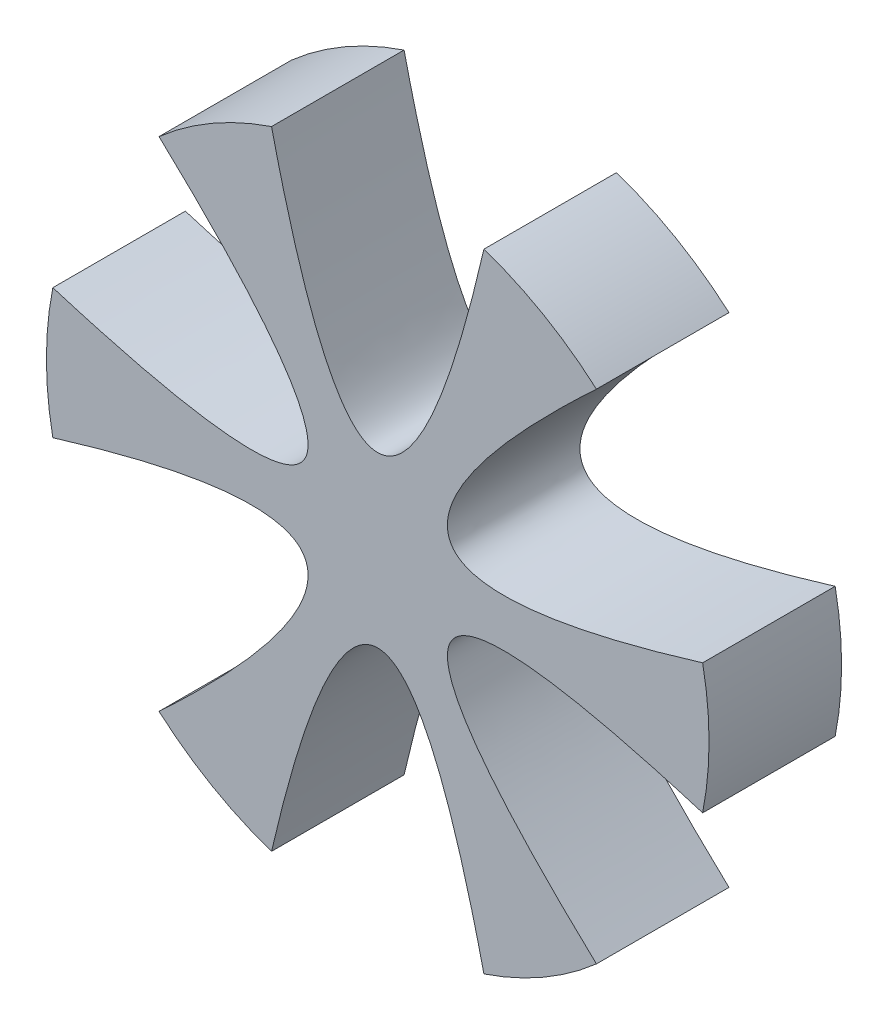
from build123d import *

# Parameters (mm, degrees)
SKETCH2_R           = 38.1
BOSS_EXTRUDE1_DEPTH = 2.54
BOSS_EXTRUDE2_DEPTH = 12.7
SKETCH4_R           = 1.524
CUT_EXTRUDE1_DEPTH  = 3.81
CUT_EXTRUDE2_DEPTH  = 46.228


with BuildPart() as part:
    # Sketch2 → Boss-Extrude1 (new body)
    with BuildSketch(Plane.XY):
        Circle(SKETCH2_R)
    extrude(amount=BOSS_EXTRUDE1_DEPTH)

    # Sketch3 → Boss-Extrude2 (add)
    with BuildSketch(Plane.XY.offset(2.54)):
        with BuildLine():
            ThreePointArc((-37.360397619, 7.470655243), (-38.1, 0), (-37.360397619, -7.470655243))
            add(Edge.make_bspline(
                [(-25.149976033, -28.619725812), (14.41186903, 8.320696464), (-37.360397619, -7.470655243)],
                knots=[0, 0, 0, 1, 1, 1], degree=2))
            ThreePointArc((-25.149976033, -28.619725812), (-19.05, -32.995567884), (-12.210421586, -36.090381055))
            add(Edge.make_bspline(
                [(12.210421586, -36.090381055), (0, 16.641392928), (-12.210421586, -36.090381055)],
                knots=[0, 0, 0, 1, 1, 1], degree=2))
            ThreePointArc((12.210421586, -36.090381055), (19.05, -32.995567884), (25.149976033, -28.619725812))
            add(Edge.make_bspline(
                [(37.360397619, -7.470655243), (-14.41186903, 8.320696464), (25.149976033, -28.619725812)],
                knots=[0, 0, 0, 1, 1, 1], degree=2))
            ThreePointArc((37.360397619, -7.470655243), (38.1, 0), (37.360397619, 7.470655243))
            add(Edge.make_bspline(
                [(25.149976033, 28.619725812), (-14.41186903, -8.320696464), (37.360397619, 7.470655243)],
                knots=[0, 0, 0, 1, 1, 1], degree=2))
            ThreePointArc((25.149976033, 28.619725812), (19.05, 32.995567884), (12.210421586, 36.090381055))
            add(Edge.make_bspline(
                [(-12.210421586, 36.090381055), (0, -16.641392928), (12.210421586, 36.090381055)],
                knots=[0, 0, 0, 1, 1, 1], degree=2))
            ThreePointArc((-12.210421586, 36.090381055), (-19.05, 32.995567884), (-25.149976033, 28.619725812))
            add(Edge.make_bspline(
                [(-37.360397619, 7.470655243), (14.41186903, -8.320696464), (-25.149976033, 28.619725812)],
                knots=[0, 0, 0, 1, 1, 1], degree=2))
        make_face()
    extrude(amount=BOSS_EXTRUDE2_DEPTH)

    # Sketch4 → Cut-Extrude1 (cut)
    with BuildSketch(Plane(origin=(0, 0, 0), x_dir=(-1, 0, 0), z_dir=(0, 0, -1))):
        Circle(SKETCH4_R)
    extrude(amount=-CUT_EXTRUDE1_DEPTH, mode=Mode.SUBTRACT)

    # Sketch6 → Cut-Extrude2 (cut)
    with BuildSketch(Plane.XY.offset(15.24)):
        with BuildLine():
            ThreePointArc((25.149976033, -28.619725812), (32.995567884, -19.05), (37.360397619, -7.470655243))
            add(Edge.make_bspline(
                [(25.149976033, -28.619725812), (-14.41186903, 8.320696464), (37.360397619, -7.470655243)],
                knots=[0, 0, 0, 1, 1, 1], degree=2))
        make_face()
        with BuildLine():
            ThreePointArc((37.360397619, 7.470655243), (32.995567884, 19.05), (25.149976033, 28.619725812))
            add(Edge.make_bspline(
                [(37.360397619, 7.470655243), (-14.41186903, -8.320696464), (25.149976033, 28.619725812)],
                knots=[0, 0, 0, 1, 1, 1], degree=2))
        make_face()
        with BuildLine():
            ThreePointArc((12.210421586, 36.090381055), (0, 38.1), (-12.210421586, 36.090381055))
            add(Edge.make_bspline(
                [(12.210421586, 36.090381055), (0, -16.641392928), (-12.210421586, 36.090381055)],
                knots=[0, 0, 0, 1, 1, 1], degree=2))
        make_face()
        with BuildLine():
            ThreePointArc((-25.149976033, 28.619725812), (-32.995567884, 19.05), (-37.360397619, 7.470655243))
            add(Edge.make_bspline(
                [(-25.149976033, 28.619725812), (14.41186903, -8.320696464), (-37.360397619, 7.470655243)],
                knots=[0, 0, 0, 1, 1, 1], degree=2))
        make_face()
        with BuildLine():
            ThreePointArc((-37.360397619, -7.470655243), (-32.995567884, -19.05), (-25.149976033, -28.619725812))
            add(Edge.make_bspline(
                [(-37.360397619, -7.470655243), (14.41186903, 8.320696464), (-25.149976033, -28.619725812)],
                knots=[0, 0, 0, 1, 1, 1], degree=2))
        make_face()
        with BuildLine():
            ThreePointArc((-12.210421586, -36.090381055), (0, -38.1), (12.210421586, -36.090381055))
            add(Edge.make_bspline(
                [(-12.210421586, -36.090381055), (0, 16.641392928), (12.210421586, -36.090381055)],
                knots=[0, 0, 0, 1, 1, 1], degree=2))
        make_face()
    extrude(amount=-CUT_EXTRUDE2_DEPTH, mode=Mode.SUBTRACT)


solid = part.part
